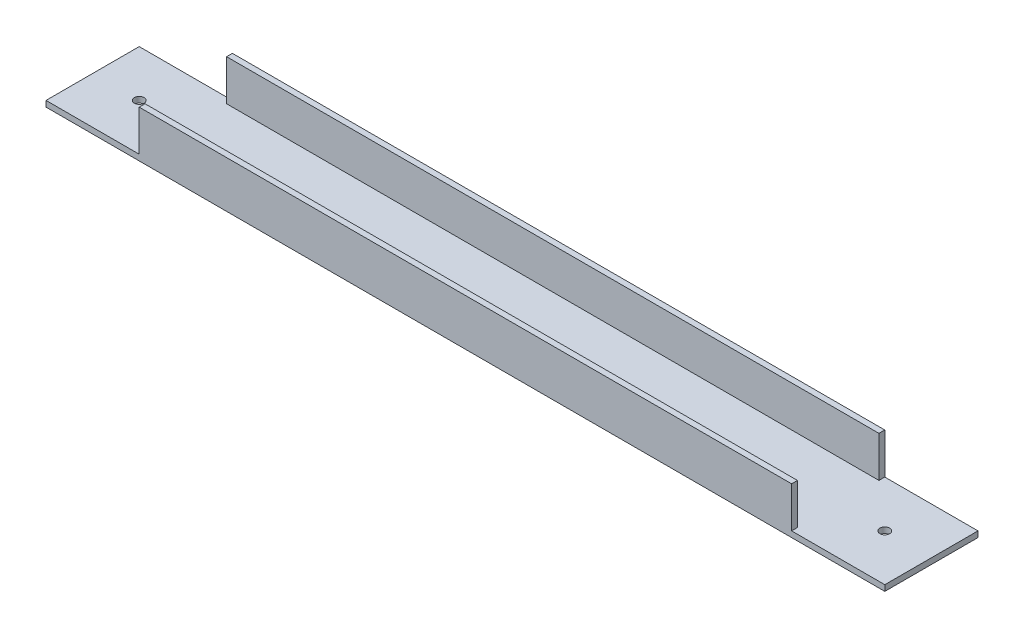
from build123d import *

# Parameters (mm, degrees)
BOSS_EXTRUDE1_DEPTH = 457.2
SKETCH2_W           = 50.8
SKETCH2_H           = 50.8
CUT_EXTRUDE1_DEPTH  = 22.225
CUT_EXTRUDE2_REACH  = 27.4
SKETCH3_R           = 2.667


with BuildPart() as part:
    # Sketch1 → Boss-Extrude1 (new body)
    with BuildSketch(Plane(origin=(0, 0, 0), x_dir=(0, 0, -1), z_dir=(1, 0, 0))):
        Polygon((3.175, 3.175), (3.175, 25.4), (0, 25.4), (0, 0), (50.8, 0), (50.8, 25.4), (47.625, 25.4), (47.625, 3.175), align=None)
    extrude(amount=BOSS_EXTRUDE1_DEPTH)

    # Sketch2 → Cut-Extrude1 (cut)
    with BuildSketch(Plane(origin=(0, 25.4, 0), x_dir=(1, 0, 0), z_dir=(0, 1, 0))):
        with Locations((25.4, 25.4)):
            Rectangle(SKETCH2_W, SKETCH2_H)
        with Locations((431.8, 25.4)):
            Rectangle(SKETCH2_W, SKETCH2_H)
    extrude(amount=-CUT_EXTRUDE1_DEPTH, mode=Mode.SUBTRACT)

    # Sketch3 → Cut-Extrude2 (cut, up to next)
    with BuildSketch(Plane.XZ, mode=Mode.PRIVATE) as cut_extrude2_sk1:
        with Locations((25.4, -25.4)):
            Circle(SKETCH3_R)
    cut_extrude2_tool1 = extrude(cut_extrude2_sk1.sketch, amount=-CUT_EXTRUDE2_REACH, mode=Mode.PRIVATE) & part.part
    add(cut_extrude2_tool1.solids().sort_by_distance((25.4, 0, -25.4))[0], mode=Mode.SUBTRACT)
    # Sketch3 → Cut-Extrude2 (cut, up to next)
    with BuildSketch(Plane.XZ, mode=Mode.PRIVATE) as cut_extrude2_sk2:
        with Locations((431.8, -25.4)):
            Circle(SKETCH3_R)
    cut_extrude2_tool2 = extrude(cut_extrude2_sk2.sketch, amount=-CUT_EXTRUDE2_REACH, mode=Mode.PRIVATE) & part.part
    add(cut_extrude2_tool2.solids().sort_by_distance((431.8, 0, -25.4))[0], mode=Mode.SUBTRACT)


solid = part.part
